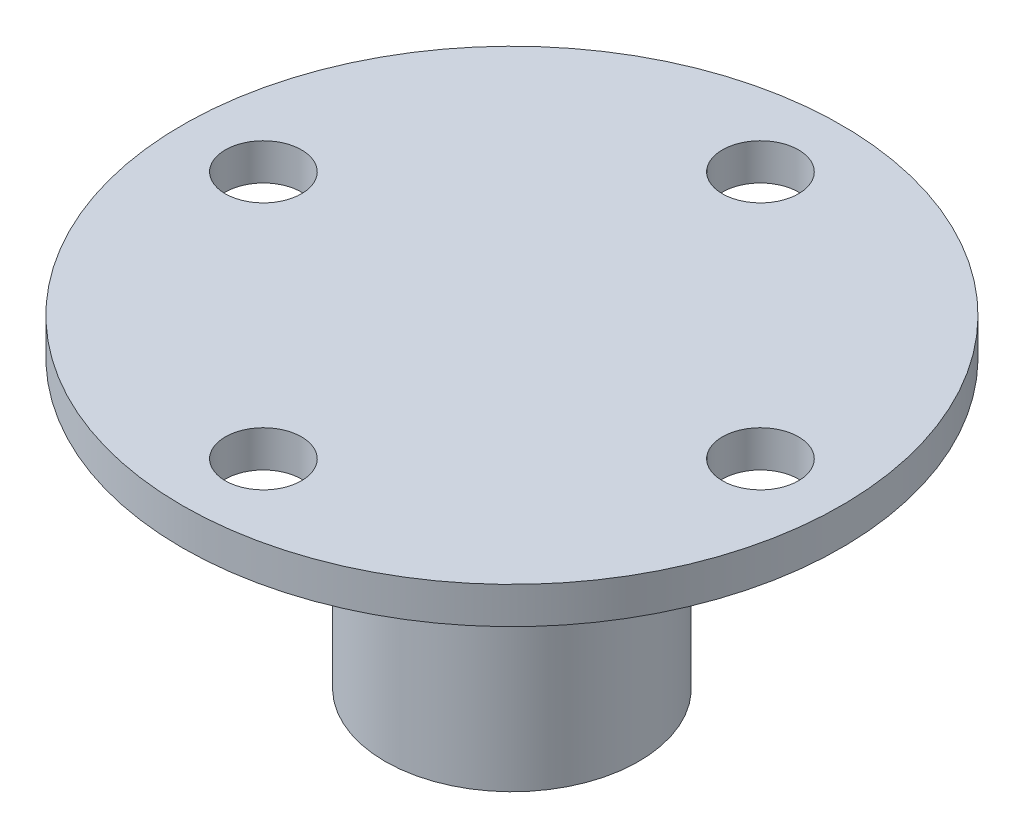
from build123d import *

# Parameters (mm, degrees)
SKETCH1_R           = 28.575
SKETCH1_R_2         = 3.302
SKETCH1_R_3         = 11
BOSS_EXTRUDE1_DEPTH = 3.175
SKETCH1_4_R         = 11
BOSS_EXTRUDE2_DEPTH = 3.175
SKETCH1_5_R         = 11
BOSS_EXTRUDE3_DEPTH = 24.825


with BuildPart() as part:
    # Sketch1 → Boss-Extrude1 (new body)
    with BuildSketch(Plane(origin=(0, 0, 0), x_dir=(1, 0, 0), z_dir=(0, 1, 0))):
        Circle(SKETCH1_R)
        with Locations((0, -21.548)):
            Circle(SKETCH1_R_2, mode=Mode.SUBTRACT)
        with Locations((-21.548, 0)):
            Circle(SKETCH1_R_2, mode=Mode.SUBTRACT)
        Circle(SKETCH1_R_3, mode=Mode.SUBTRACT)
        with BuildLine():
            ThreePointArc((24.85, 0), (21.548, -3.302), (18.246, 0))
            ThreePointArc((18.246, 0), (21.548, 3.302), (24.85, 0))
        make_face(mode=Mode.SUBTRACT)
        with Locations((0, 21.548)):
            Circle(SKETCH1_R_2, mode=Mode.SUBTRACT)
    extrude(amount=BOSS_EXTRUDE1_DEPTH)

    # Sketch1_4 → Boss-Extrude2 (add)
    with BuildSketch(Plane(origin=(0, 0, 0), x_dir=(1, 0, 0), z_dir=(0, 1, 0))):
        Circle(SKETCH1_4_R)
    extrude(amount=BOSS_EXTRUDE2_DEPTH)

    # Sketch1_5 → Boss-Extrude3 (add)
    with BuildSketch(Plane(origin=(0, 0, 0), x_dir=(1, 0, 0), z_dir=(0, 1, 0))):
        Circle(SKETCH1_5_R)
        with BuildLine():
            ThreePointArc((-5.414213562, -2.585786438), (-1.325654296, 5.851721173), (6, 0))
            ThreePointArc((6, 0), (3.200412581, -5.075170865), (-2.585786438, -5.414213562))
            Line((-2.585786438, -5.414213562), (-3.889087297, -6.717514421))
            Line((-3.889087297, -6.717514421), (-6.717514421, -3.889087297))
            Line((-6.717514421, -3.889087297), (-5.414213562, -2.585786438))
        make_face(mode=Mode.SUBTRACT)
    extrude(amount=-BOSS_EXTRUDE3_DEPTH)


solid = part.part
